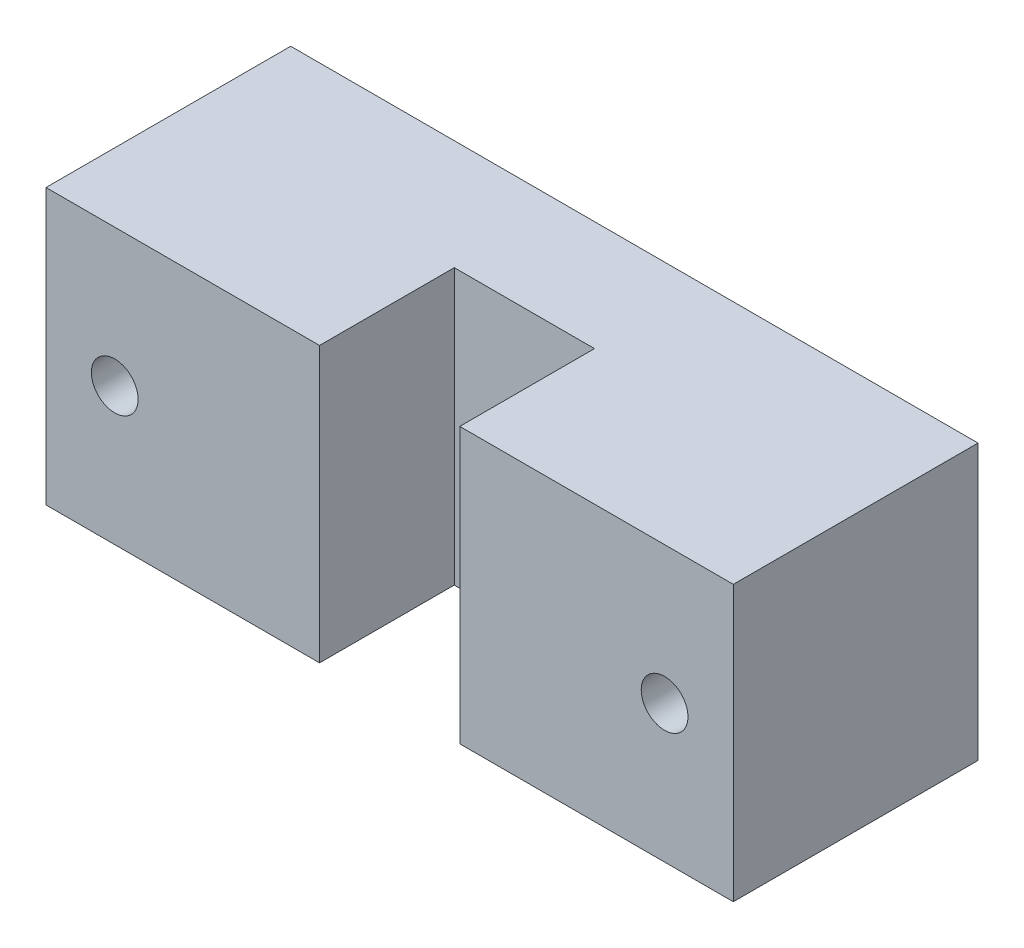
from build123d import *

# Parameters (mm, degrees)
SKETCH2_W           = 50
SKETCH2_H           = 20
SKETCH2_R           = 1.7
BOSS_EXTRUDE1_DEPTH = 8
BOSS_EXTRUDE2_DEPTH = 20
SKETCH6_R           = 3.75
CUT_EXTRUDE1_DEPTH  = 4
SKETCH7_R           = 1.7
CUT_EXTRUDE2_DEPTH  = 18.8


with BuildPart() as part:
    # Sketch2 → Boss-Extrude1 (new body)
    with BuildSketch(Plane.XY):
        Rectangle(SKETCH2_W, SKETCH2_H)
        with Locations((-20, 0)):
            Circle(SKETCH2_R, mode=Mode.SUBTRACT)
        with Locations((20, 0)):
            Circle(SKETCH2_R, mode=Mode.SUBTRACT)
    extrude(amount=BOSS_EXTRUDE1_DEPTH)

    # Sketch5 → Boss-Extrude2 (add)
    with BuildSketch(Plane.XZ.offset(10)):
        with BuildLine():
            Line((-25, 8), (-25, 17.8))
            Line((-25, 17.8), (-5.1, 17.8))
            Line((-5.1, 17.8), (-5.1, 8))
            Line((-5.1, 8), (5.1, 8))
            Line((5.1, 8), (5.1, 17.8))
            Line((5.1, 17.8), (25, 17.8))
            Line((25, 17.8), (25, 8))
            ThreePointArc((25, 8), (0, 0), (-25, 8))
        make_face()
    extrude(amount=-BOSS_EXTRUDE2_DEPTH)

    # Sketch6 → Cut-Extrude1 (cut)
    with BuildSketch(Plane(origin=(0, 0, 0), x_dir=(-1, 0, 0), z_dir=(0, 0, -1))):
        with Locations((20, 0)):
            Circle(SKETCH6_R)
        with Locations((-20, 0)):
            Circle(SKETCH6_R)
    extrude(amount=-CUT_EXTRUDE1_DEPTH, mode=Mode.SUBTRACT)

    # Sketch7 → Cut-Extrude2 (cut, through all)
    with BuildSketch(Plane(origin=(0, 0, 0), x_dir=(-1, 0, 0), z_dir=(0, 0, -1))):
        with Locations((20, 0)):
            Circle(SKETCH7_R)
        with Locations((-20, 0)):
            Circle(SKETCH7_R)
    extrude(amount=-CUT_EXTRUDE2_DEPTH, mode=Mode.SUBTRACT)


solid = part.part
